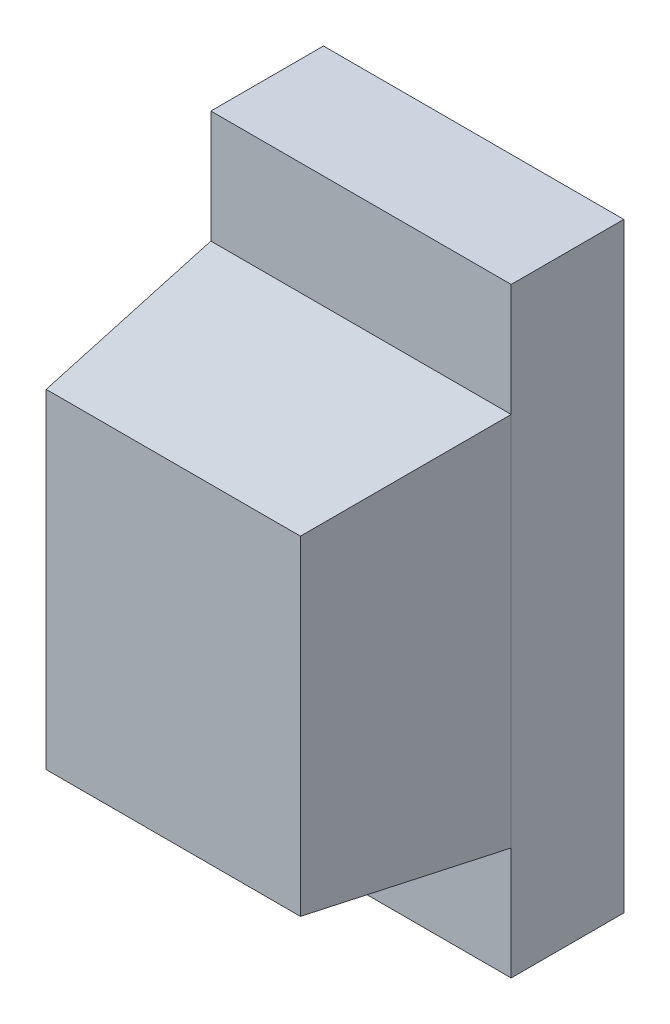
from build123d import *

# Parameters (mm, degrees)
SKETCH1_W           = 0.8
SKETCH1_H           = 1.6
BOSS_EXTRUDE1_DEPTH = 0.3
SKETCH3_W           = 0.8
SKETCH3_H           = 1
BOSS_EXTRUDE3_DEPTH = 0.5
BOSS_EXTRUDE3_TAPER = 7


with BuildPart() as part:
    # Sketch1 → Boss-Extrude1 (new body)
    with BuildSketch(Plane.XY):
        Rectangle(SKETCH1_W, SKETCH1_H)
    extrude(amount=BOSS_EXTRUDE1_DEPTH)

    # Sketch3 → Boss-Extrude3 (add)
    with BuildSketch(Plane.XY.offset(0.3)):
        Rectangle(SKETCH3_W, SKETCH3_H)
    extrude(amount=BOSS_EXTRUDE3_DEPTH, taper=BOSS_EXTRUDE3_TAPER)


solid = part.part
